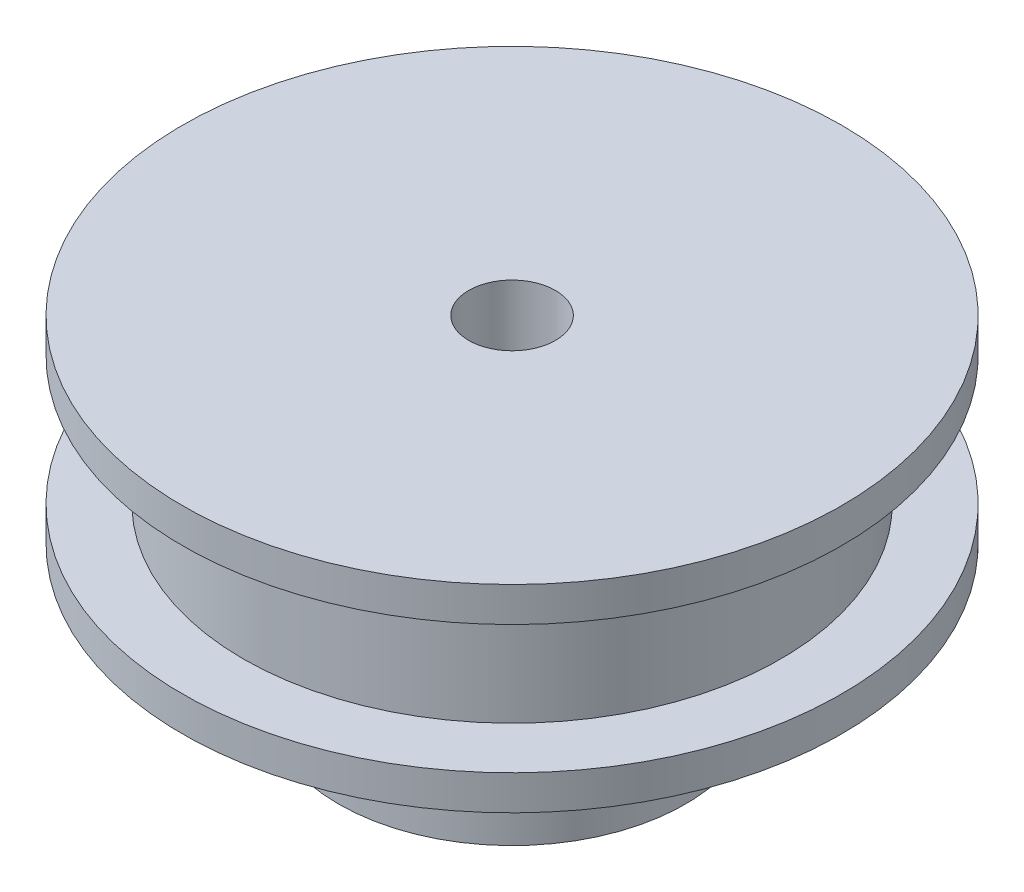
from build123d import *


with BuildPart() as part:
    # Эскиз1 → Повернуть1 (revolve)
    with BuildSketch(Plane.XY):
        Polygon((-2.5, 19.4), (-19, 19.4), (-19, 17.4), (-15.5, 17.4), (-15.5, 10), (-19, 10), (-19, 8), (-10, 8), (-10, 0), (-2.5, 0), align=None)
    revolve(axis=Axis((0, 0, 0), (0, 1, 0)))


solid = part.part
